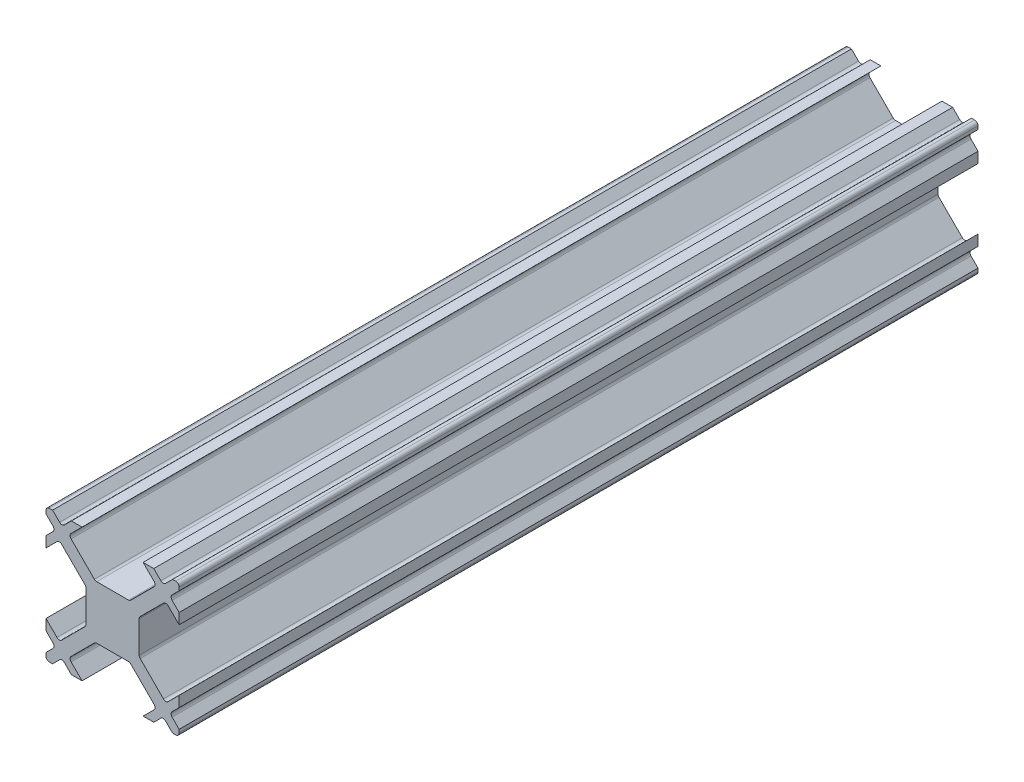
from build123d import *

# Parameters (mm, degrees)
BOSS_EXTRUDE1_DEPTH = 60


with BuildPart() as part:
    # Sketch1 → Boss-Extrude1 (new body)
    with BuildSketch(Plane.XY.offset(12.5)):
        with BuildLine():
            Line((1.189339828, 2), (-1.189339828, 2))
            ThreePointArc((-1.189339828, 2), (-1.285010686, 2.019030117), (-1.366116524, 2.073223305))
            Line((-1.366116524, 2.073223305), (-3.116116524, 3.823223305))
            ThreePointArc((-3.116116524, 3.823223305), (-3.189339828, 4), (-3.116116524, 4.176776695))
            Line((-3.116116524, 4.176776695), (-2.292893219, 5))
            Line((-2.292893219, 5), (-3.094974747, 5))
            Line((-3.094974747, 5), (-3.623223305, 4.471751442))
            ThreePointArc((-3.623223305, 4.471751442), (-3.8, 4.398528137), (-3.976776695, 4.471751442))
            Line((-3.976776695, 4.471751442), (-4.505025253, 5))
            Line((-4.505025253, 5), (-4.75, 5))
            ThreePointArc((-4.75, 5), (-4.926776695, 4.926776695), (-5, 4.75))
            Line((-5, 4.75), (-5, 4.505025253))
            Line((-5, 4.505025253), (-4.471751442, 3.976776695))
            ThreePointArc((-4.471751442, 3.976776695), (-4.398528137, 3.8), (-4.471751442, 3.623223305))
            Line((-4.471751442, 3.623223305), (-5, 3.094974747))
            Line((-5, 3.094974747), (-5, 2.292893219))
            Line((-5, 2.292893219), (-4.176776695, 3.116116524))
            ThreePointArc((-4.176776695, 3.116116524), (-4, 3.189339828), (-3.823223305, 3.116116524))
            Line((-3.823223305, 3.116116524), (-2.073223305, 1.366116524))
            ThreePointArc((-2.073223305, 1.366116524), (-2.019030117, 1.285010686), (-2, 1.189339828))
            Line((-2, 1.189339828), (-2, -1.189339828))
            ThreePointArc((-2, -1.189339828), (-2.019030117, -1.285010686), (-2.073223305, -1.366116524))
            Line((-2.073223305, -1.366116524), (-3.823223305, -3.116116524))
            ThreePointArc((-3.823223305, -3.116116524), (-4, -3.189339828), (-4.176776695, -3.116116524))
            Line((-4.176776695, -3.116116524), (-5, -2.292893219))
            Line((-5, -2.292893219), (-5, -3.094974747))
            Line((-5, -3.094974747), (-4.471751442, -3.623223305))
            ThreePointArc((-4.471751442, -3.623223305), (-4.398528137, -3.8), (-4.471751442, -3.976776695))
            Line((-4.471751442, -3.976776695), (-5, -4.505025253))
            Line((-5, -4.505025253), (-5, -4.75))
            ThreePointArc((-5, -4.75), (-4.926776695, -4.926776695), (-4.75, -5))
            Line((-4.75, -5), (-4.505025253, -5))
            Line((-4.505025253, -5), (-3.976776695, -4.471751442))
            ThreePointArc((-3.976776695, -4.471751442), (-3.8, -4.398528137), (-3.623223305, -4.471751442))
            Line((-3.623223305, -4.471751442), (-3.094974747, -5))
            Line((-3.094974747, -5), (-2.292893219, -5))
            Line((-2.292893219, -5), (-3.116116524, -4.176776695))
            ThreePointArc((-3.116116524, -4.176776695), (-3.189339828, -4), (-3.116116524, -3.823223305))
            Line((-3.116116524, -3.823223305), (-1.366116524, -2.073223305))
            ThreePointArc((-1.366116524, -2.073223305), (-1.285010686, -2.019030117), (-1.189339828, -2))
            Line((-1.189339828, -2), (1.189339828, -2))
            ThreePointArc((1.189339828, -2), (1.285010686, -2.019030117), (1.366116524, -2.073223305))
            Line((1.366116524, -2.073223305), (3.116116524, -3.823223305))
            ThreePointArc((3.116116524, -3.823223305), (3.189339828, -4), (3.116116524, -4.176776695))
            Line((3.116116524, -4.176776695), (2.292893219, -5))
            Line((2.292893219, -5), (3.094974747, -5))
            Line((3.094974747, -5), (3.623223305, -4.471751442))
            ThreePointArc((3.623223305, -4.471751442), (3.8, -4.398528137), (3.976776695, -4.471751442))
            Line((3.976776695, -4.471751442), (4.505025253, -5))
            Line((4.505025253, -5), (4.75, -5))
            ThreePointArc((4.75, -5), (4.926776695, -4.926776695), (5, -4.75))
            Line((5, -4.75), (5, -4.505025253))
            Line((5, -4.505025253), (4.471751442, -3.976776695))
            ThreePointArc((4.471751442, -3.976776695), (4.398528137, -3.8), (4.471751442, -3.623223305))
            Line((4.471751442, -3.623223305), (5, -3.094974747))
            Line((5, -3.094974747), (5, -2.292893219))
            Line((5, -2.292893219), (4.176776695, -3.116116524))
            ThreePointArc((4.176776695, -3.116116524), (4, -3.189339828), (3.823223305, -3.116116524))
            Line((3.823223305, -3.116116524), (2.073223305, -1.366116524))
            ThreePointArc((2.073223305, -1.366116524), (2.019030117, -1.285010686), (2, -1.189339828))
            Line((2, -1.189339828), (2, 1.189339828))
            ThreePointArc((2, 1.189339828), (2.019030117, 1.285010686), (2.073223305, 1.366116524))
            Line((2.073223305, 1.366116524), (3.823223305, 3.116116524))
            ThreePointArc((3.823223305, 3.116116524), (4, 3.189339828), (4.176776695, 3.116116524))
            Line((4.176776695, 3.116116524), (5, 2.292893219))
            Line((5, 2.292893219), (5, 3.094974747))
            Line((5, 3.094974747), (4.471751442, 3.623223305))
            ThreePointArc((4.471751442, 3.623223305), (4.398528137, 3.8), (4.471751442, 3.976776695))
            Line((4.471751442, 3.976776695), (5, 4.505025253))
            Line((5, 4.505025253), (5, 4.75))
            ThreePointArc((5, 4.75), (4.926776695, 4.926776695), (4.75, 5))
            Line((4.75, 5), (4.505025253, 5))
            Line((4.505025253, 5), (3.976776695, 4.471751442))
            ThreePointArc((3.976776695, 4.471751442), (3.8, 4.398528137), (3.623223305, 4.471751442))
            Line((3.623223305, 4.471751442), (3.094974747, 5))
            Line((3.094974747, 5), (2.292893219, 5))
            Line((2.292893219, 5), (3.116116524, 4.176776695))
            ThreePointArc((3.116116524, 4.176776695), (3.189339828, 4), (3.116116524, 3.823223305))
            Line((3.116116524, 3.823223305), (1.366116524, 2.073223305))
            ThreePointArc((1.366116524, 2.073223305), (1.285010686, 2.019030117), (1.189339828, 2))
        make_face()
    extrude(amount=-BOSS_EXTRUDE1_DEPTH)


solid = part.part
